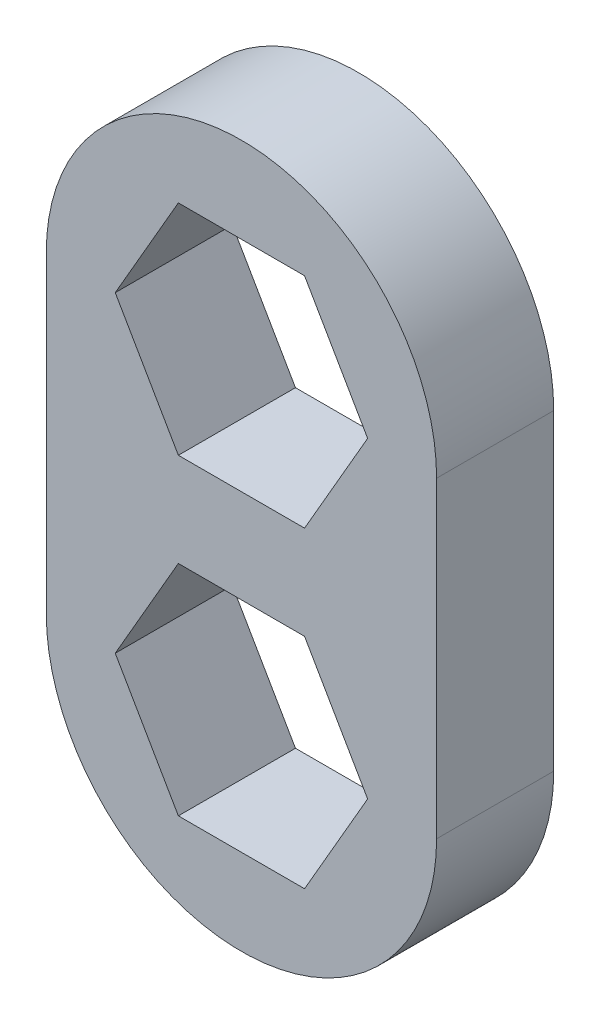
from build123d import *

# Parameters (mm, degrees)
BOSS_EXTRUDE1_DEPTH = 3


with BuildPart() as part:
    # Sketch1 → Boss-Extrude1 (new body)
    with BuildSketch(Plane.XY):
        with BuildLine():
            Line((-5, -4), (-5, 4))
            ThreePointArc((-5, 4), (0, 9), (5, 4))
            Line((5, 4), (5, -4))
            ThreePointArc((5, -4), (0, -9), (-5, -4))
        make_face()
        Polygon((1.616580754, 1.2), (3.233161507, 4), (1.616580754, 6.8), (-1.616580754, 6.8), (-3.233161507, 4), (-1.616580754, 1.2), align=None, mode=Mode.SUBTRACT)
        Polygon((3.233161507, -4), (1.616580754, -1.2), (-1.616580754, -1.2), (-3.233161507, -4), (-1.616580754, -6.8), (1.616580754, -6.8), align=None, mode=Mode.SUBTRACT)
    extrude(amount=BOSS_EXTRUDE1_DEPTH)


solid = part.part
